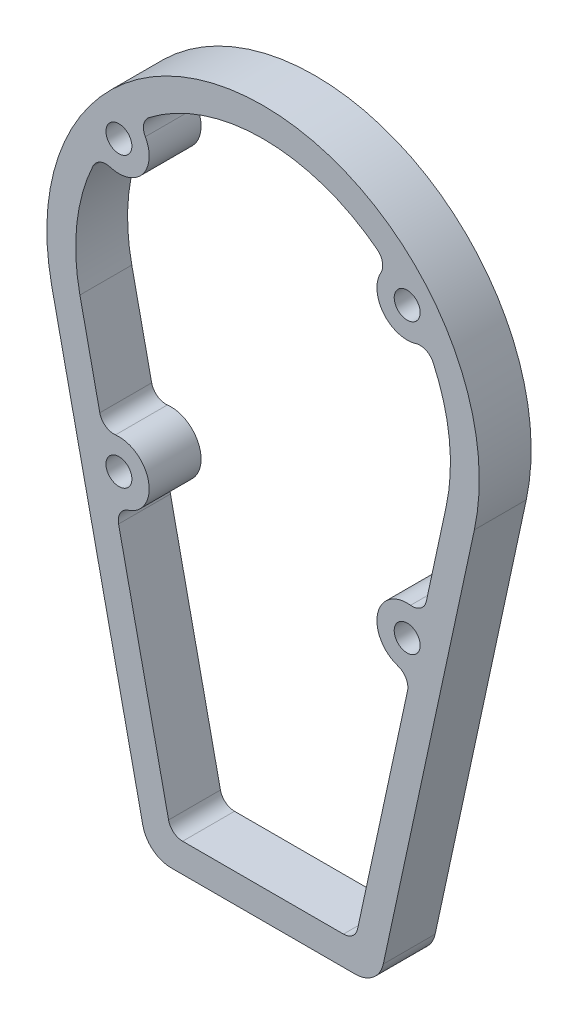
from build123d import *

# Parameters (mm, degrees)
SKETCH3_R           = 4.5
BOSS_EXTRUDE1_DEPTH = 18
FILLET1_R           = 5
FILLET2_R           = 5


with BuildPart() as part:
    # Sketch3 → Boss-Extrude1 (new body)
    with BuildSketch(Plane.XY):
        with BuildLine():
            Line((-31.929873349, -122.5), (31.929873349, -122.5))
            ThreePointArc((31.929873349, -122.5), (38.210043039, -120.281996444), (41.704324989, -114.611893732))
            Line((41.704324989, -114.611893732), (73.308387301, 31.660797012))
            ThreePointArc((73.308387301, 31.660797012), (0, 122.5), (-73.308387301, 31.660797012))
            Line((-73.308387301, 31.660797012), (-41.704324989, -114.611893732))
            ThreePointArc((-41.704324989, -114.611893732), (-38.210043039, -120.281996444), (-31.929873349, -122.5))
        make_face()
        with Locations((50, -12.5)):
            Circle(SKETCH3_R, mode=Mode.SUBTRACT)
        with Locations((50, 87.5)):
            Circle(SKETCH3_R, mode=Mode.SUBTRACT)
        with Locations((-50, 87.5)):
            Circle(SKETCH3_R, mode=Mode.SUBTRACT)
        with Locations((-50, -12.5)):
            Circle(SKETCH3_R, mode=Mode.SUBTRACT)
        with BuildLine():
            Line((-31.929873349, -112.5), (-51.284518999, -22.921132901))
            ThreePointArc((-51.284518999, -22.921132901), (-39.736825778, -10.282511582), (-55.472323677, -3.538768301))
            Line((-55.472323677, -3.538768301), (-63.533935661, 33.772690744))
            ThreePointArc((-63.533935661, 33.772690744), (-64.271528905, 57.204152316), (-56.648842383, 79.373322021))
            ThreePointArc((-56.648842383, 79.373322021), (-41.800877501, 80.940702001), (-43.531035666, 95.770580418))
            ThreePointArc((-43.531035666, 95.770580418), (0, 112.5), (43.531035666, 95.770580418))
            ThreePointArc((43.531035666, 95.770580418), (41.800877501, 80.940702001), (56.648842383, 79.373322021))
            ThreePointArc((56.648842383, 79.373322021), (64.271528905, 57.204152316), (63.533935661, 33.772690744))
            Line((63.533935661, 33.772690744), (55.472323677, -3.538768301))
            ThreePointArc((55.472323677, -3.538768301), (39.736825778, -10.282511582), (51.284518999, -22.921132901))
            Line((51.284518999, -22.921132901), (31.929873349, -112.5))
            Line((31.929873349, -112.5), (-31.929873349, -112.5))
        make_face(mode=Mode.SUBTRACT)
    extrude(amount=BOSS_EXTRUDE1_DEPTH)

    # Fillet1
    fillet1_edges = [part.edges().sort_by_distance(p)[0] for p in [
        (-31.929873349, -112.5, 9),
        (31.929873349, -112.5, 9),
    ]]
    fillet(fillet1_edges, radius=FILLET1_R)

    # Fillet2
    fillet2_edges = [part.edges().sort_by_distance(p)[0] for p in [
        (51.284518999, -22.921132901, 9),
        (55.472323677, -3.538768301, 9),
        (56.648842383, 79.373322021, 9),
        (43.531035666, 95.770580418, 9),
        (-43.531035666, 95.770580418, 9),
        (-56.648842383, 79.373322021, 9),
        (-55.472323677, -3.538768301, 9),
        (-51.284518999, -22.921132901, 9),
    ]]
    fillet(fillet2_edges, radius=FILLET2_R)


solid = part.part
